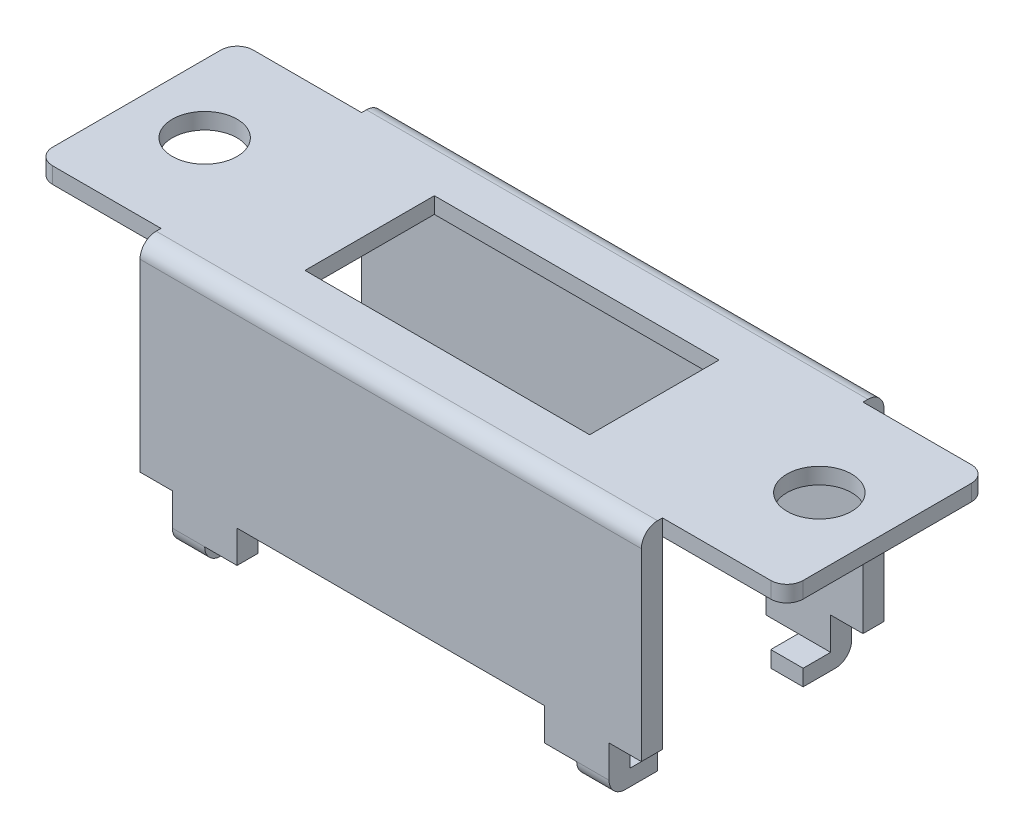
from build123d import *

# Parameters (mm, degrees)
SKETCH1_R           = 1
SKETCH1_W           = 8.8
SKETCH1_H           = 4
BOSS_EXTRUDE1_DEPTH = 0.5
SKETCH2_W           = 15.5
SKETCH2_H           = 0.65
BOSS_EXTRUDE2_DEPTH = 5.7
SKETCH5_W           = 2
SKETCH5_H           = 0.65
BOSS_EXTRUDE4_DEPTH = 1
SKETCH6_W           = 1
SKETCH6_H           = 0.5
BOSS_EXTRUDE5_DEPTH = 1.5
FILLET1_R           = 0.5
SKETCH7_W           = 1
SKETCH7_H           = 0.5
BOSS_EXTRUDE6_DEPTH = 1.5
FILLET2_R           = 0.5


with BuildPart() as part:
    # Sketch1 → Boss-Extrude1 (new body)
    with BuildSketch(Plane(origin=(0, 0, 0), x_dir=(1, 0, 0), z_dir=(0, 1, 0))):
        with BuildLine():
            Line((11.6, 2.6), (11.6, -2.6))
            ThreePointArc((11.6, -2.6), (11.453553391, -2.953553391), (11.1, -3.1))
            Line((11.1, -3.1), (7.75, -3.1))
            Line((7.75, -3.1), (7.75, -3.75))
            Line((7.75, -3.75), (-7.75, -3.75))
            Line((-7.75, -3.75), (-7.75, -3.1))
            Line((-7.75, -3.1), (-11.1, -3.1))
            ThreePointArc((-11.1, -3.1), (-11.453553391, -2.953553391), (-11.6, -2.6))
            Line((-11.6, -2.6), (-11.6, 2.6))
            ThreePointArc((-11.6, 2.6), (-11.453553391, 2.953553391), (-11.1, 3.1))
            Line((-11.1, 3.1), (-7.75, 3.1))
            Line((-7.75, 3.1), (-7.75, 3.75))
            Line((-7.75, 3.75), (7.75, 3.75))
            Line((7.75, 3.75), (7.75, 3.1))
            Line((7.75, 3.1), (11.1, 3.1))
            ThreePointArc((11.1, 3.1), (11.453553391, 2.953553391), (11.6, 2.6))
        make_face()
        with Locations((9.5, 0)):
            Circle(SKETCH1_R, mode=Mode.SUBTRACT)
        with Locations((-9.5, 0)):
            Circle(SKETCH1_R, mode=Mode.SUBTRACT)
        Rectangle(SKETCH1_W, SKETCH1_H, mode=Mode.SUBTRACT)
    extrude(amount=-BOSS_EXTRUDE1_DEPTH)

    # Sketch2 → Boss-Extrude2 (add)
    with BuildSketch(Plane.XZ.offset(0.5)):
        with Locations((0, 3.425)):
            Rectangle(SKETCH2_W, SKETCH2_H)
        with Locations((0, -3.425)):
            Rectangle(SKETCH2_W, SKETCH2_H)
    extrude(amount=BOSS_EXTRUDE2_DEPTH)

    # Sketch5 → Boss-Extrude4 (add)
    with BuildSketch(Plane.XZ.offset(6.2)):
        with Locations((-5.75, 3.425)):
            Rectangle(SKETCH5_W, SKETCH5_H)
        with Locations((-5.75, -3.425)):
            Rectangle(SKETCH5_W, SKETCH5_H)
        with Locations((5.75, -3.425)):
            Rectangle(SKETCH5_W, SKETCH5_H)
        with Locations((5.75, 3.425)):
            Rectangle(SKETCH5_W, SKETCH5_H)
    extrude(amount=BOSS_EXTRUDE4_DEPTH)

    # Sketch6 → Boss-Extrude5 (add)
    with BuildSketch(Plane(origin=(0, 0, -3.75), x_dir=(-1, 0, 0), z_dir=(0, 0, -1))):
        with Locations((-6.25, -7.45)):
            Rectangle(SKETCH6_W, SKETCH6_H)
        with Locations((6.25, -7.45)):
            Rectangle(SKETCH6_W, SKETCH6_H)
    extrude(amount=-BOSS_EXTRUDE5_DEPTH)

    # Fillet1
    fillet1_edges = [part.edges().sort_by_distance(p)[0] for p in [
        (-6.25, -7.7, -3.75),
        (6.25, -7.7, -3.75),
        (0, 0, -3.75),
    ]]
    fillet(fillet1_edges, radius=FILLET1_R)

    # Sketch7 → Boss-Extrude6 (add)
    with BuildSketch(Plane.XY.offset(3.75)):
        with Locations((-6.25, -7.45)):
            Rectangle(SKETCH7_W, SKETCH7_H)
        with Locations((6.25, -7.45)):
            Rectangle(SKETCH7_W, SKETCH7_H)
    extrude(amount=-BOSS_EXTRUDE6_DEPTH)

    # Fillet2
    fillet2_edges = [part.edges().sort_by_distance(p)[0] for p in [
        (0, 0, 3.75),
        (6.25, -7.7, 3.75),
        (-6.25, -7.7, 3.75),
    ]]
    fillet(fillet2_edges, radius=FILLET2_R)


solid = part.part
